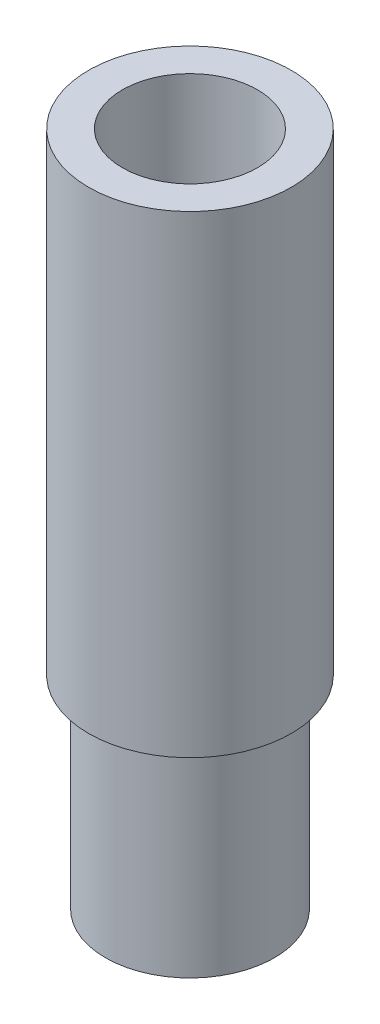
from build123d import *

# Parameters (mm, degrees)
SKETCH1_R           = 6.25
BOSS_EXTRUDE1_DEPTH = 15
SKETCH3_R           = 7.5
BOSS_EXTRUDE2_DEPTH = 35
SKETCH4_R           = 5
CUT_EXTRUDE1_DEPTH  = 25
SKETCH5_R           = 2.5
CUT_EXTRUDE2_DEPTH  = 35


with BuildPart() as part:
    # Sketch1 → Boss-Extrude1 (new body)
    with BuildSketch(Plane(origin=(0, 0, 0), x_dir=(1, 0, 0), z_dir=(0, 1, 0))):
        Circle(SKETCH1_R)
    extrude(amount=BOSS_EXTRUDE1_DEPTH)

    # Sketch3 → Boss-Extrude2 (add)
    with BuildSketch(Plane(origin=(0, 15, 0), x_dir=(1, 0, 0), z_dir=(0, 1, 0))):
        Circle(SKETCH3_R)
    extrude(amount=BOSS_EXTRUDE2_DEPTH)

    # Sketch4 → Cut-Extrude1 (cut)
    with BuildSketch(Plane(origin=(0, 50, 0), x_dir=(1, 0, 0), z_dir=(0, 1, 0))):
        Circle(SKETCH4_R)
    extrude(amount=-CUT_EXTRUDE1_DEPTH, mode=Mode.SUBTRACT)

    # Sketch5 → Cut-Extrude2 (cut)
    with BuildSketch(Plane(origin=(0, 0, 0), x_dir=(-1, 0, 0), z_dir=(0, -1, 0))):
        Circle(SKETCH5_R)
    extrude(amount=-CUT_EXTRUDE2_DEPTH, mode=Mode.SUBTRACT)


solid = part.part
